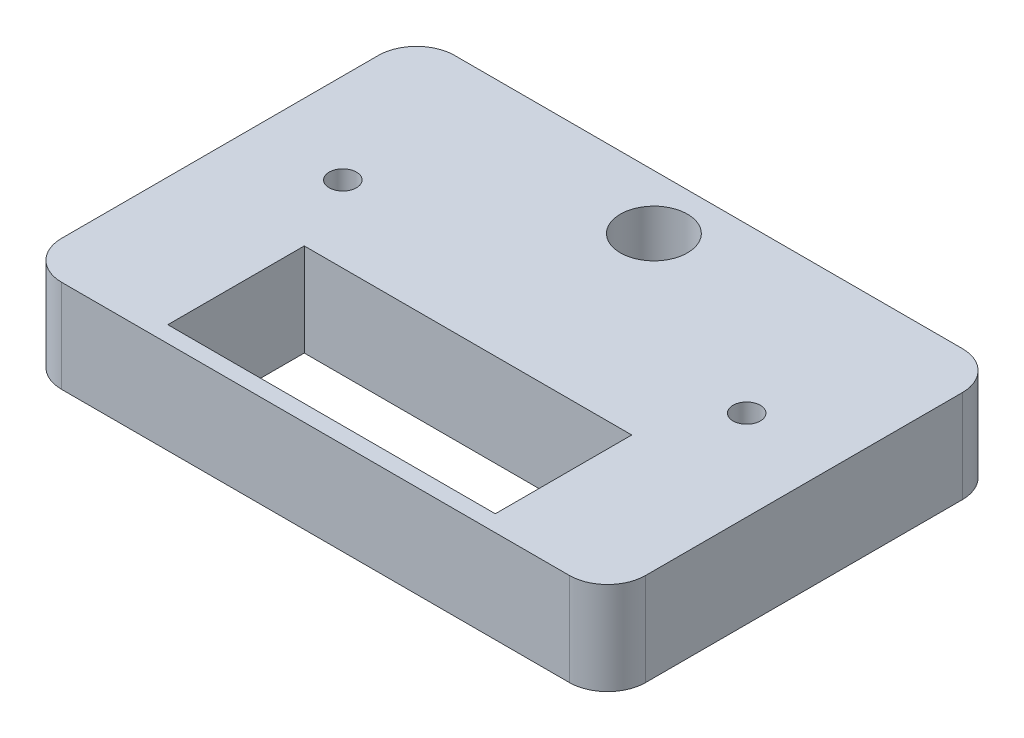
from build123d import *

# Parameters (mm, degrees)
SKETCH2_W           = 53.5
SKETCH2_H           = 36
BOSS_EXTRUDE1_DEPTH = 8.5
CUT_EXTRUDE15_DEPTH = 0.2
SKETCH16_R          = 3.075
CUT_EXTRUDE16_DEPTH = 11.1
SKETCH13_R          = 1.25
CUT_EXTRUDE18_DEPTH = 5
FILLET1_R           = 3.5
SKETCH27_W          = 30
SKETCH27_H          = 12.5
CUT_EXTRUDE20_DEPTH = 21


with BuildPart() as part:
    # Sketch2 → Boss-Extrude1 (new body)
    with BuildSketch(Plane(origin=(0, 0, 0), x_dir=(1, 0, 0), z_dir=(0, 1, 0))):
        Rectangle(SKETCH2_W, SKETCH2_H)
    extrude(amount=BOSS_EXTRUDE1_DEPTH)

    # Sketch25 → Cut-Extrude15 (cut)
    with BuildSketch(Plane.XZ):
        Polygon((-3.903846154, -7.486705173), (-3.903846154, -6.768756455), (-5.294871795, -6.768756455), (-5.294871795, -6.187526487), (-3.814803686, -4.031576968), (-3.230769231, -4.031576968), (-3.230769231, -6.185423122), (-2.782051282, -6.185423122), (-2.782051282, -6.768756455), (-3.230769231, -6.768756455), (-3.230769231, -7.486705173), align=None)
        Polygon((-3.903846154, -6.185423122), (-3.903846154, -5.020158699), (-4.704527244, -6.185423122), align=None, mode=Mode.SUBTRACT)
        with BuildLine():
            add(Edge.make_bspline(
                [(-1.368589744, -3.986705173), (-1.326928083, -3.987710025), (-1.245817604, -3.989666357), (-1.127630705, -4.006995919), (-1.016351859, -4.034782904), (-0.91198923, -4.074061777), (-0.814640589, -4.125067663), (-0.724954376, -4.188018532), (-0.640970826, -4.261027366), (-0.592473395, -4.317683431), (-0.567908654, -4.346380654)],
                knots=[0, 0, 0, 0, 1.098584764, 2.138818609, 3.143716932, 4.11936356, 5.073598562, 6.034819447, 7.004603936, 8, 8, 8, 8], degree=3))
            add(Edge.make_bspline(
                [(-0.567908654, -4.346380654), (-0.553857229, -4.364656994), (-0.525180735, -4.401955801), (-0.486559942, -4.462226554), (-0.449431305, -4.526160527), (-0.417021628, -4.595296637), (-0.385987958, -4.668435141), (-0.35722857, -4.745742689), (-0.33225769, -4.827858025), (-0.308761552, -4.91373116), (-0.289614355, -5.004703227), (-0.271920573, -5.099792126), (-0.257251633, -5.199428938), (-0.245684307, -5.303294882), (-0.23535354, -5.41123193), (-0.22969278, -5.523755147), (-0.225057824, -5.640613277), (-0.224594604, -5.720106685), (-0.224358974, -5.760543314)],
                knots=[0, 0, 0, 0, 0.746761706, 1.524009783, 2.317797294, 3.140957436, 3.996208027, 4.892396322, 5.812273159, 6.776774596, 7.776522781, 8.823794876, 9.910947555, 11.039215469, 12.21036455, 13.424061321, 14.689674014, 16, 16, 16, 16], degree=3))
            add(Edge.make_bspline(
                [(-0.224358974, -5.760543314), (-0.224591055, -5.800980037), (-0.225045956, -5.880240056), (-0.22971006, -5.996863747), (-0.235358586, -6.109152356), (-0.245660207, -6.217095169), (-0.257338284, -6.320940466), (-0.271587832, -6.420465588), (-0.290613096, -6.515117551), (-0.309459084, -6.605944523), (-0.332817473, -6.692183283), (-0.358910499, -6.77415136), (-0.386513972, -6.85242262), (-0.418269178, -6.925655279), (-0.451841723, -6.994876942), (-0.488417818, -7.059463498), (-0.527469844, -7.120107774), (-0.556423766, -7.157603354), (-0.570713141, -7.176108218)],
                knots=[0, 0, 0, 0, 1.308387162, 2.564569672, 3.776470597, 4.945886788, 6.07248526, 7.158029334, 8.197718558, 9.195987466, 10.159061779, 11.087054987, 11.979325145, 12.84323098, 13.668471539, 14.467659354, 15.243757377, 16, 16, 16, 16], degree=3))
            add(Edge.make_bspline(
                [(-0.570713141, -7.176108218), (-0.595053131, -7.204559465), (-0.643101444, -7.260723599), (-0.726155494, -7.333126962), (-0.815693026, -7.394775924), (-0.912870203, -7.444768192), (-1.01672288, -7.484318094), (-1.128183832, -7.511218395), (-1.246047857, -7.528583236), (-1.327159819, -7.530564823), (-1.368589744, -7.531576968)],
                knots=[0, 0, 0, 0, 0.991631672, 1.957528776, 2.911425699, 3.867574088, 4.848108326, 5.850523106, 6.902101959, 8, 8, 8, 8], degree=3))
            add(Edge.make_bspline(
                [(-1.368589744, -7.531576968), (-1.410493198, -7.530371211), (-1.492605187, -7.528008467), (-1.612492251, -7.509278324), (-1.726450408, -7.47927275), (-1.83407055, -7.436432791), (-1.935198692, -7.380915347), (-2.030624887, -7.314365242), (-2.118273049, -7.233769068), (-2.186891995, -7.158738477), (-2.237093823, -7.090942821), (-2.272500858, -7.034724237), (-2.306717985, -6.974568108), (-2.336251478, -6.908593652), (-2.365388893, -6.838752195), (-2.391195487, -6.763538558), (-2.413963588, -6.683599505), (-2.435341386, -6.599300061), (-2.45316732, -6.510059568), (-2.469564562, -6.416141376), (-2.482486474, -6.317146077), (-2.49394308, -6.213625061), (-2.502009186, -6.105333956), (-2.508559893, -5.992449973), (-2.511844622, -5.874611777), (-2.51249086, -5.794432387), (-2.512820513, -5.753532096)],
                knots=[0, 0, 0, 0, 1.257818097, 2.464759732, 3.634271214, 4.790227596, 5.933394726, 7.09190477, 8.274482889, 9.50191983, 10.139172818, 10.805000628, 11.49619854, 12.215266328, 12.973768034, 13.768328009, 14.601232062, 15.469317089, 16.379095881, 17.333267023, 18.331755967, 19.376479622, 20.460535752, 21.592206075, 22.771760786, 24, 24, 24, 24], degree=3))
            add(Edge.make_bspline(
                [(-2.512820513, -5.753532096), (-2.512590285, -5.713328922), (-2.512139069, -5.634535868), (-2.507440953, -5.518381848), (-2.501867072, -5.406554323), (-2.491453325, -5.298857562), (-2.479939041, -5.195455696), (-2.465425472, -5.096212397), (-2.446873234, -5.001641133), (-2.426673864, -4.911364453), (-2.404516535, -4.825062645), (-2.378180942, -4.743457095), (-2.350853361, -4.665313562), (-2.318727003, -4.592471527), (-2.285360573, -4.523395554), (-2.248755858, -4.4588211), (-2.209711035, -4.398173779), (-2.180756181, -4.360678593), (-2.166466346, -4.342173923)],
                knots=[0, 0, 0, 0, 1.304469132, 2.556591843, 3.77188756, 4.93702727, 6.066781583, 7.147865049, 8.190466662, 9.19316792, 10.149665317, 11.080258032, 11.975027628, 12.834388201, 13.661940433, 14.463366943, 15.241638981, 16, 16, 16, 16], degree=3))
            add(Edge.make_bspline(
                [(-2.166466346, -4.342173923), (-2.142127695, -4.31371994), (-2.094082024, -4.257550403), (-2.01100863, -4.185186592), (-1.921372105, -4.123271527), (-1.823910533, -4.073877643), (-1.720295929, -4.03378553), (-1.608980846, -4.007099888), (-1.491135601, -3.989689216), (-1.41002101, -3.987714042), (-1.368589744, -3.986705173)],
                knots=[0, 0, 0, 0, 0.991667276, 1.957599061, 2.911530233, 3.873218945, 4.847995157, 5.850445929, 6.902062539, 8, 8, 8, 8], degree=3))
        make_face()
        with BuildLine():
            add(Edge.make_bspline(
                [(-1.368589744, -4.570038506), (-1.389932177, -4.5710165), (-1.43214946, -4.572951061), (-1.493511342, -4.587288039), (-1.551462579, -4.610947176), (-1.606282532, -4.643975026), (-1.656759821, -4.689921308), (-1.699518607, -4.75152541), (-1.736446, -4.82712386), (-1.754926132, -4.883630585), (-1.764723558, -4.913588186)],
                knots=[0, 0, 0, 0, 0.899391665, 1.779078861, 2.640979247, 3.529945348, 4.464599804, 5.495588918, 6.672261578, 8, 8, 8, 8], degree=3))
            add(Edge.make_bspline(
                [(-1.764723558, -4.913588186), (-1.770842219, -4.936192025), (-1.783992841, -4.984773657), (-1.798918251, -5.063981908), (-1.811226929, -5.153874888), (-1.821620364, -5.254431705), (-1.830078429, -5.365705573), (-1.835287197, -5.487767293), (-1.838887403, -5.620531337), (-1.839450599, -5.712630596), (-1.83974359, -5.760543314)],
                knots=[0, 0, 0, 0, 0.658986521, 1.416336438, 2.266694271, 3.212608458, 4.261595115, 5.407496572, 6.651304179, 8, 8, 8, 8], degree=3))
            add(Edge.make_bspline(
                [(-1.83974359, -5.760543314), (-1.839344149, -5.808219008), (-1.838578489, -5.899605318), (-1.836404267, -6.030772731), (-1.830232701, -6.150172041), (-1.824055561, -6.258279068), (-1.813767259, -6.354753178), (-1.803419368, -6.439854882), (-1.789156502, -6.513002973), (-1.769695646, -6.592564668), (-1.740263596, -6.675838606), (-1.699883702, -6.759849788), (-1.656582644, -6.827306833), (-1.605581762, -6.875605627), (-1.550383864, -6.908005643), (-1.493132577, -6.931811637), (-1.431826573, -6.945170034), (-1.389917557, -6.947207005), (-1.368589744, -6.948243635)],
                knots=[0, 0, 0, 0, 1.613353868, 3.092528792, 4.438413522, 5.658843895, 6.755779493, 7.721003256, 8.558527904, 9.275869043, 10.491421475, 11.538327284, 12.426656321, 13.187490948, 13.890032692, 14.581719216, 15.278226227, 16, 16, 16, 16], degree=3))
            add(Edge.make_bspline(
                [(-1.368589744, -6.948243635), (-1.347001862, -6.947315243), (-1.304755202, -6.945498417), (-1.243312926, -6.930683413), (-1.185279177, -6.907735685), (-1.130826037, -6.874034437), (-1.080396026, -6.828402759), (-1.037668455, -6.766743298), (-1.000731191, -6.691162354), (-0.982252559, -6.634652968), (-0.972455929, -6.604693955)],
                knots=[0, 0, 0, 0, 0.909107913, 1.77908945, 2.650019014, 3.530482969, 4.465025013, 5.495890128, 6.672421267, 8, 8, 8, 8], degree=3))
            add(Edge.make_bspline(
                [(-0.972455929, -6.604693955), (-0.966346119, -6.582088323), (-0.953274381, -6.533724313), (-0.938242616, -6.455009155), (-0.925900615, -6.365581997), (-0.915606, -6.265482613), (-0.907064739, -6.154449107), (-0.901900187, -6.032617599), (-0.898296595, -5.900087968), (-0.897729977, -5.808222359), (-0.897435897, -5.760543314)],
                knots=[0, 0, 0, 0, 0.66114423, 1.414496391, 2.261103113, 3.210114492, 4.255954433, 5.405607896, 6.653488082, 8, 8, 8, 8], degree=3))
            add(Edge.make_bspline(
                [(-0.897435897, -5.760543314), (-0.897403381, -5.712862628), (-0.897341048, -5.621459551), (-0.901470839, -5.490125647), (-0.905523867, -5.37037463), (-0.913788683, -5.262441084), (-0.922066625, -5.165960491), (-0.934398702, -5.081415894), (-0.9468223, -5.007875459), (-0.968054257, -4.92847956), (-0.99690866, -4.844966309), (-1.036329232, -4.760082155), (-1.080890103, -4.693257451), (-1.131521329, -4.644137945), (-1.18644754, -4.611025771), (-1.24383933, -4.587147538), (-1.305040593, -4.572974708), (-1.347250858, -4.571024441), (-1.368589744, -4.570038506)],
                knots=[0, 0, 0, 0, 1.611146624, 3.088541111, 4.440175916, 5.659517762, 6.746360572, 7.711365618, 8.546319149, 9.264661039, 10.486047304, 11.528122518, 12.419721574, 13.184982167, 13.89070983, 14.574167459, 15.279187713, 16, 16, 16, 16], degree=3))
        make_face(mode=Mode.SUBTRACT)
        with BuildLine():
            Line((1.884615385, -7.486705173), (1.211538462, -7.486705173))
            Line((1.211538462, -7.486705173), (1.211538462, -4.994918314))
            add(Edge.make_bspline(
                [(1.211538462, -4.994918314), (1.181031, -5.025889079), (1.120429942, -5.087410457), (1.023640507, -5.173224576), (0.923158317, -5.253054333), (0.817989008, -5.32614149), (0.709507412, -5.393527411), (0.596604909, -5.454680395), (0.480099855, -5.510446579), (0.399391759, -5.541611213), (0.358974359, -5.557217994)],
                knots=[0, 0, 0, 0, 1.012567276, 2.011397996, 3.011400399, 4.000747768, 4.993445519, 5.985067596, 6.990952157, 8, 8, 8, 8], degree=3))
            Line((0.358974359, -5.557217994), (0.358974359, -4.884141071))
            add(Edge.make_bspline(
                [(0.358974359, -4.884141071), (0.403799291, -4.867333645), (0.497614386, -4.83215701), (0.636053917, -4.757334525), (0.780553521, -4.664696739), (0.901941437, -4.573840525), (0.998318452, -4.493062089), (1.065678659, -4.428128902), (1.128091763, -4.36163395), (1.183211781, -4.29143102), (1.232485639, -4.21893946), (1.276144425, -4.144277698), (1.314574193, -4.067209883), (1.334691908, -4.013541565), (1.344751603, -3.986705173)],
                knots=[0, 0, 0, 0, 1.253673617, 2.623841347, 4.114270668, 5.751233548, 6.594491912, 7.409089316, 8.202422231, 8.983165545, 9.746111525, 10.498431446, 11.249153235, 12, 12, 12, 12], degree=3))
            Line((1.344751603, -3.986705173), (1.884615385, -3.986705173))
            Line((1.884615385, -3.986705173), (1.884615385, -7.486705173))
        make_face()
        with BuildLine():
            Line((2.961538462, -6.618716391), (3.634615385, -6.544397481))
            add(Edge.make_bspline(
                [(3.634615385, -6.544397481), (3.63902273, -6.576622392), (3.647353518, -6.63753409), (3.673992044, -6.721118182), (3.707379529, -6.792865481), (3.752751025, -6.850602482), (3.80689694, -6.894672006), (3.86891104, -6.926472037), (3.939040806, -6.94478976), (3.988339544, -6.947063642), (4.013922276, -6.948243635)],
                knots=[0, 0, 0, 0, 1.261142327, 2.383817955, 3.394783384, 4.319218401, 5.209639591, 6.086630953, 7.00709008, 8, 8, 8, 8], degree=3))
            add(Edge.make_bspline(
                [(4.013922276, -6.948243635), (4.030575888, -6.947857642), (4.063488187, -6.947094809), (4.11163489, -6.936340189), (4.158225996, -6.921262941), (4.202781273, -6.89919575), (4.244874775, -6.870795558), (4.285550283, -6.836703434), (4.323560138, -6.795826441), (4.36131506, -6.748907074), (4.395489343, -6.691268688), (4.425650076, -6.621359382), (4.453810367, -6.539198539), (4.476942475, -6.443764372), (4.497763568, -6.335879367), (4.515876812, -6.215198266), (4.530572355, -6.081647327), (4.537067584, -5.988202995), (4.540464744, -5.939329372)],
                knots=[0, 0, 0, 0, 0.636702566, 1.258306339, 1.881198412, 2.509855161, 3.155497192, 3.822694, 4.538353708, 5.290656154, 6.125969777, 7.095962945, 8.203044623, 9.449504243, 10.854253673, 12.411741228, 14.12325476, 16, 16, 16, 16], degree=3))
            add(Edge.make_bspline(
                [(4.540464744, -5.939329372), (4.518932329, -5.962440395), (4.476478048, -6.008007131), (4.406164047, -6.067788881), (4.331297762, -6.118049701), (4.252262202, -6.15856169), (4.169881896, -6.191660132), (4.082802441, -6.213431691), (3.992236312, -6.228369145), (3.930317828, -6.229647209), (3.898938301, -6.230294917)],
                knots=[0, 0, 0, 0, 1.041520616, 2.053509057, 3.037255372, 4.009786987, 4.979165048, 5.959157055, 6.965725879, 8, 8, 8, 8], degree=3))
            add(Edge.make_bspline(
                [(3.898938301, -6.230294917), (3.86453903, -6.229308371), (3.796620542, -6.227360519), (3.696702638, -6.213214026), (3.600431432, -6.189090687), (3.507653226, -6.155638151), (3.418837041, -6.11129855), (3.332850369, -6.059023177), (3.25153839, -5.995747095), (3.173714687, -5.925043991), (3.103728689, -5.845447425), (3.04122538, -5.760098126), (2.988334966, -5.668526669), (2.945674242, -5.570830382), (2.912680904, -5.467631116), (2.888693491, -5.35901554), (2.874677888, -5.244417686), (2.872769008, -5.166030503), (2.871794872, -5.12602809)],
                knots=[0, 0, 0, 0, 0.980269742, 1.935460739, 2.869230488, 3.804804075, 4.740187949, 5.694100724, 6.667990488, 7.67211685, 8.68661751, 9.683203946, 10.682901945, 11.694007529, 12.71565541, 13.766145059, 14.860022949, 16, 16, 16, 16], degree=3))
            add(Edge.make_bspline(
                [(2.871794872, -5.12602809), (2.872681312, -5.084379002), (2.874420128, -5.00268131), (2.889674764, -4.88357356), (2.912971882, -4.77019346), (2.947758633, -4.663545751), (2.991045709, -4.562485032), (3.044847914, -4.468278677), (3.107382914, -4.379616372), (3.180457817, -4.299134566), (3.25989152, -4.225461297), (3.34558143, -4.161349118), (3.437030427, -4.107769537), (3.533428321, -4.063242986), (3.635498258, -4.028951018), (3.742587891, -4.004513893), (3.854801355, -3.989361595), (3.931374999, -3.987602758), (3.970452724, -3.986705173)],
                knots=[0, 0, 0, 0, 1.1238417, 2.204496613, 3.236450213, 4.243990082, 5.227299393, 6.199188572, 7.167261658, 8.150145869, 9.127934804, 10.088143708, 11.032722787, 11.984040773, 12.949643861, 13.93368149, 14.945498424, 16, 16, 16, 16], degree=3))
            add(Edge.make_bspline(
                [(3.970452724, -3.986705173), (4.013054872, -3.987882306), (4.096592666, -3.990190524), (4.219026597, -4.0094114), (4.335196854, -4.042113662), (4.446257752, -4.085966847), (4.550608483, -4.14439), (4.649606619, -4.214901428), (4.741929454, -4.298940663), (4.829193387, -4.394843437), (4.908588931, -4.505658389), (4.976186424, -4.63373174), (5.033685521, -4.777850809), (5.080096797, -4.938325095), (5.116361767, -5.115113454), (5.141391414, -5.308212487), (5.158139778, -5.517660446), (5.159533517, -5.662818124), (5.16025641, -5.738107417)],
                knots=[0, 0, 0, 0, 0.854852685, 1.67626545, 2.479841517, 3.273455256, 4.067207639, 4.874322592, 5.708061326, 6.568303409, 7.473035808, 8.43640186, 9.467839227, 10.582672616, 11.785182758, 13.086903962, 14.489057258, 16, 16, 16, 16], degree=3))
            add(Edge.make_bspline(
                [(5.16025641, -5.738107417), (5.159211576, -5.814561497), (5.157192912, -5.962273967), (5.140905065, -6.175516666), (5.115124374, -6.372413189), (5.07721978, -6.552611733), (5.029652102, -6.71676024), (4.969838473, -6.864233428), (4.900175362, -6.995791874), (4.818625461, -7.110224221), (4.72897261, -7.209678809), (4.63261292, -7.29584035), (4.529408259, -7.368449028), (4.420254235, -7.429014159), (4.303518757, -7.474368866), (4.180817214, -7.50722745), (4.051819535, -7.528512854), (3.963526397, -7.530543177), (3.918569712, -7.531576968)],
                knots=[0, 0, 0, 0, 1.487495966, 2.873904204, 4.158892752, 5.348685137, 6.453750751, 7.479786756, 8.440129076, 9.343583348, 10.206541379, 11.040779453, 11.853317241, 12.65721927, 13.463689683, 14.283322899, 15.125910407, 16, 16, 16, 16], degree=3))
            add(Edge.make_bspline(
                [(3.918569712, -7.531576968), (3.886291417, -7.530912693), (3.8229599, -7.529609354), (3.730238134, -7.519123906), (3.642256803, -7.50090359), (3.559308753, -7.475457975), (3.480746608, -7.444167749), (3.407237353, -7.404470874), (3.338761835, -7.357274715), (3.274154073, -7.304029843), (3.216009511, -7.242310159), (3.162523434, -7.174167085), (3.114542892, -7.098918759), (3.073679293, -7.01591839), (3.035958158, -6.927091478), (3.005572195, -6.830469246), (2.980229697, -6.727141985), (2.967878904, -6.65549653), (2.961538462, -6.618716391)],
                knots=[0, 0, 0, 0, 1.056675019, 2.073245589, 3.050223185, 3.994251036, 4.910773036, 5.814621688, 6.723026041, 7.630269412, 8.550362125, 9.493303905, 10.463425011, 11.466105649, 12.519144845, 13.620215273, 14.778306119, 16, 16, 16, 16], degree=3))
        make_face()
        with BuildLine():
            add(Edge.make_bspline(
                [(4.487179487, -5.142855013), (4.486931575, -5.120625448), (4.486449759, -5.077422284), (4.478255962, -5.014856657), (4.466367381, -4.956267519), (4.450621966, -4.901004907), (4.428638608, -4.849982478), (4.402564014, -4.802396792), (4.371753816, -4.758629422), (4.324323442, -4.707499601), (4.259940816, -4.652463391), (4.173693803, -4.604658548), (4.08105885, -4.574852014), (4.016947073, -4.571656832), (3.98447516, -4.570038506)],
                knots=[0, 0, 0, 0, 0.937516427, 1.822063352, 2.657744432, 3.45986214, 4.242145632, 4.997087526, 5.746986504, 6.494090859, 7.936347984, 9.300605415, 10.632786197, 12, 12, 12, 12], degree=3))
            add(Edge.make_bspline(
                [(3.98447516, -4.570038506), (3.954164593, -4.571412852), (3.895168362, -4.574087868), (3.810731863, -4.598129741), (3.734241069, -4.637150429), (3.678525395, -4.682673309), (3.638819807, -4.726092771), (3.613934121, -4.764986816), (3.592744344, -4.808339816), (3.57520082, -4.8565214), (3.561357866, -4.909557677), (3.55154309, -4.967731506), (3.546200387, -5.030574417), (3.545323584, -5.074135392), (3.544871795, -5.096580974)],
                knots=[0, 0, 0, 0, 1.397188569, 2.719475933, 4.017809812, 5.337496372, 6.01771949, 6.727108146, 7.460709441, 8.242571956, 9.09066939, 9.98839818, 10.963485712, 12, 12, 12, 12], degree=3))
            add(Edge.make_bspline(
                [(3.544871795, -5.096580974), (3.545233367, -5.119502707), (3.545932165, -5.163802735), (3.552487242, -5.227981159), (3.562320959, -5.287529625), (3.57829482, -5.341983189), (3.597062895, -5.392117027), (3.619726565, -5.438083544), (3.648507116, -5.478184717), (3.690081977, -5.525749127), (3.75090794, -5.574166513), (3.833380926, -5.616384172), (3.924489648, -5.64248396), (3.988274388, -5.645445311), (4.020933494, -5.646961583)],
                knots=[0, 0, 0, 0, 1.000122719, 1.932902026, 2.813346472, 3.630219284, 4.405058741, 5.14865055, 5.858963796, 6.55275156, 7.902081098, 9.220520156, 10.576848858, 12, 12, 12, 12], degree=3))
            add(Edge.make_bspline(
                [(4.020933494, -5.646961583), (4.052671839, -5.64571798), (4.114601406, -5.643291393), (4.202710274, -5.61737353), (4.283594526, -5.577618427), (4.342770508, -5.530698904), (4.385073763, -5.486258937), (4.412300983, -5.448095032), (4.435772891, -5.406325365), (4.454517397, -5.360578923), (4.4692595, -5.311253), (4.479640231, -5.258428189), (4.486087199, -5.20190921), (4.486807395, -5.162972049), (4.487179487, -5.142855013)],
                knots=[0, 0, 0, 0, 1.470045212, 2.868431389, 4.227473852, 5.634383908, 6.348475288, 7.071419378, 7.805118666, 8.569021284, 9.362200428, 10.192314795, 11.06605236, 12, 12, 12, 12], degree=3))
        make_face(mode=Mode.SUBTRACT)
    extrude(amount=-CUT_EXTRUDE15_DEPTH, mode=Mode.SUBTRACT)

    # Sketch16 → Cut-Extrude16 (cut)
    with BuildSketch(Plane(origin=(0, 8.5, 0), x_dir=(1, 0, 0), z_dir=(0, 1, 0))):
        with Locations(Location((0, 13, 0), (0, 0, 270))):
            Circle(SKETCH16_R)
    extrude(amount=-CUT_EXTRUDE16_DEPTH, mode=Mode.SUBTRACT)

    # Sketch13 → Cut-Extrude18 (cut)
    with BuildSketch(Plane(origin=(0, 8.5, 0), x_dir=(1, 0, 0), z_dir=(0, 1, 0))):
        with Locations(Location((-18.5, 3, 0), (0, 0, 270))):
            Circle(SKETCH13_R)
        with Locations(Location((18.5, 3, 0), (0, 0, 90))):
            Circle(SKETCH13_R)
    extrude(amount=-CUT_EXTRUDE18_DEPTH, mode=Mode.SUBTRACT)

    # Fillet1
    fillet1_edges = [part.edges().sort_by_distance(p)[0] for p in [
        (-26.75, 4.25, -18),
        (26.75, 4.25, -18),
        (26.75, 4.25, 18),
        (-26.75, 4.25, 18),
    ]]
    fillet(fillet1_edges, radius=FILLET1_R)

    # Sketch27 → Cut-Extrude20 (cut)
    with BuildSketch(Plane(origin=(0, 8.5, 0), x_dir=(1, 0, 0), z_dir=(0, 1, 0))):
        with Locations((-0.030560767, -10.25)):
            Rectangle(SKETCH27_W, SKETCH27_H)
    extrude(amount=-CUT_EXTRUDE20_DEPTH, mode=Mode.SUBTRACT)


solid = part.part
